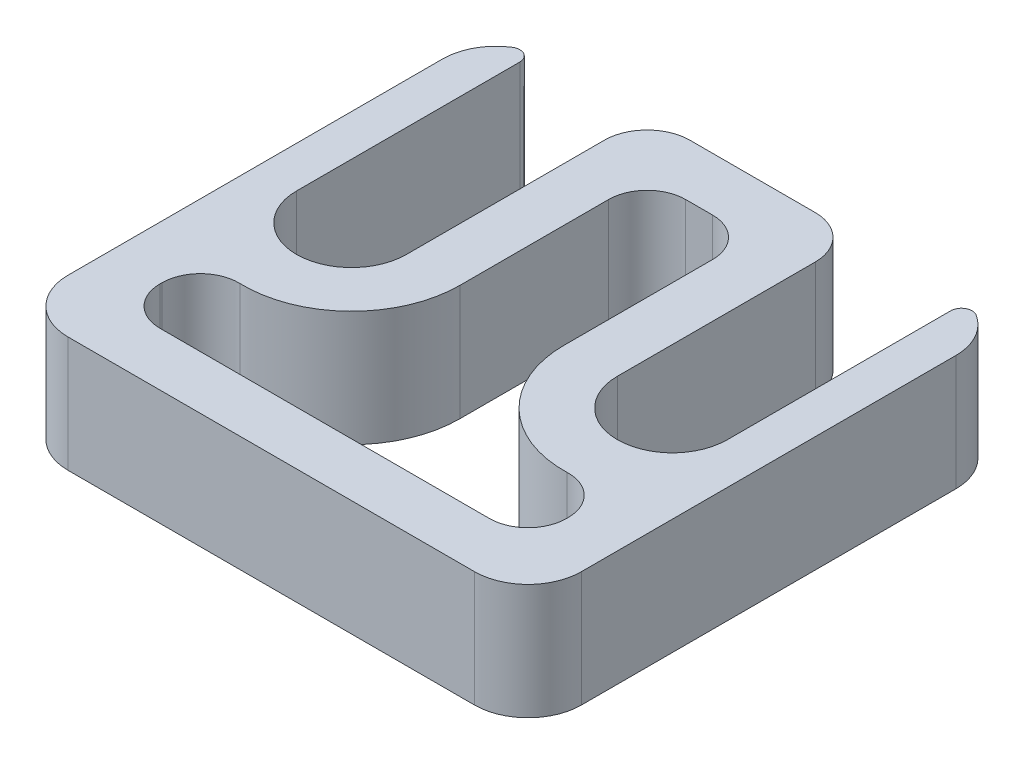
from build123d import *

# Parameters (mm, degrees)
BOSS_EXTRUDE1_DEPTH     = 6.858
FILLET1_R               = 2.54
FILLET2_R               = 0.635
CUT_EXTRUDE1_DEPTH      = 308.470862171
CUT_EXTRUDE1_DEPTH_BACK = 308.470862171
FILLET3_R               = 2.286


with BuildPart() as part:
    # Sketch1 → Boss-Extrude1 (new body)
    with BuildSketch(Plane(origin=(0, 546.1, 533.938575125), x_dir=(1, 0, 0), z_dir=(0, -1, 0))):
        with BuildLine():
            Line((21.5011, -242.346575125), (21.5011, -256.634075125))
            Line((21.5011, -256.634075125), (8.9789, -256.634075125))
            Line((8.9789, -256.634075125), (8.9789, -242.346575125))
            ThreePointArc((8.9789, -242.346575125), (5.715, -239.082675125), (2.4511, -242.346575125))
            Line((2.4511, -242.346575125), (2.4511, -256.550449219))
            ThreePointArc((2.4511, -256.550449219), (0.687128671, -255.431667645), (0, -253.459075125))
            Line((0, -253.459075125), (0, -231.234075125))
            ThreePointArc((0, -231.234075125), (0.92993597, -228.989011095), (3.175, -228.059075125))
            Line((3.175, -228.059075125), (27.305, -228.059075125))
            ThreePointArc((27.305, -228.059075125), (29.55006403, -228.989011095), (30.48, -231.234075125))
            Line((30.48, -231.234075125), (30.48, -253.459075125))
            ThreePointArc((30.48, -253.459075125), (29.792871329, -255.431667645), (28.0289, -256.550449219))
            Line((28.0289, -256.550449219), (28.0289, -242.346575125))
            ThreePointArc((28.0289, -242.346575125), (24.765, -239.082675125), (21.5011, -242.346575125))
        make_face()
    extrude(amount=-BOSS_EXTRUDE1_DEPTH)

    # Fillet1
    fillet1_edges = [part.edges().sort_by_distance(p)[0] for p in [
        (21.5011, 549.529, 277.3045),
        (8.9789, 549.529, 277.3045),
    ]]
    fillet(fillet1_edges, radius=FILLET1_R)

    # Fillet2
    fillet2_edges = [part.edges().sort_by_distance(p)[0] for p in [
        (28.0289, 549.529, 277.388125906),
        (2.4511, 549.529, 277.388125906),
    ]]
    fillet(fillet2_edges, radius=FILLET2_R)

    # Sketch2 → Cut-Extrude1 (cut, two sides)
    with BuildSketch(Plane.XZ.offset(-546.1)) as cut_extrude1_sk:
        with BuildLine():
            Line((27.305, 297.508741773), (27.305, 302.7045))
            Line((27.305, 302.7045), (3.175, 302.7045))
            Line((3.175, 302.7045), (3.175, 297.508741773))
            ThreePointArc((3.175, 297.508741773), (9.257924442, 296.968534163), (12.1539, 291.592))
            Line((12.1539, 291.592), (12.1539, 280.4795))
            Line((12.1539, 280.4795), (18.3261, 280.4795))
            Line((18.3261, 280.4795), (18.3261, 291.592))
            ThreePointArc((18.3261, 291.592), (21.222075558, 296.968534163), (27.305, 297.508741773))
        make_face()
    extrude(amount=CUT_EXTRUDE1_DEPTH, mode=Mode.SUBTRACT)
    extrude(cut_extrude1_sk.sketch, amount=-CUT_EXTRUDE1_DEPTH_BACK, mode=Mode.SUBTRACT)

    # Fillet3
    fillet3_edges = [part.edges().sort_by_distance(p)[0] for p in [
        (27.305, 549.529, 297.508741773),
        (18.3261, 549.529, 280.4795),
        (12.1539, 549.529, 280.4795),
        (3.175, 549.529, 297.508741773),
        (3.175, 549.529, 302.7045),
        (27.305, 549.529, 302.7045),
    ]]
    fillet(fillet3_edges, radius=FILLET3_R)


solid = part.part
